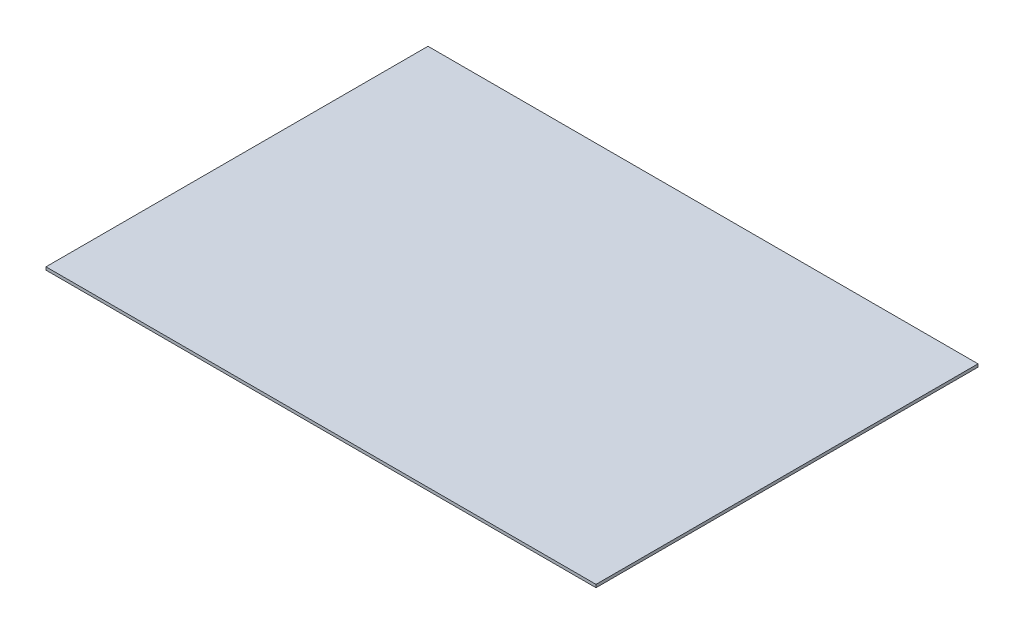
from build123d import *

# Parameters (mm, degrees)
SKETCH1_W           = 561.55
SKETCH1_H           = 3
BOSS_EXTRUDE1_DEPTH = 390


with BuildPart() as part:
    # Sketch1 → Boss-Extrude1 (new body)
    with BuildSketch(Plane.XY):
        with Locations((280.775, 1.5)):
            Rectangle(SKETCH1_W, SKETCH1_H)
    extrude(amount=BOSS_EXTRUDE1_DEPTH)


solid = part.part
